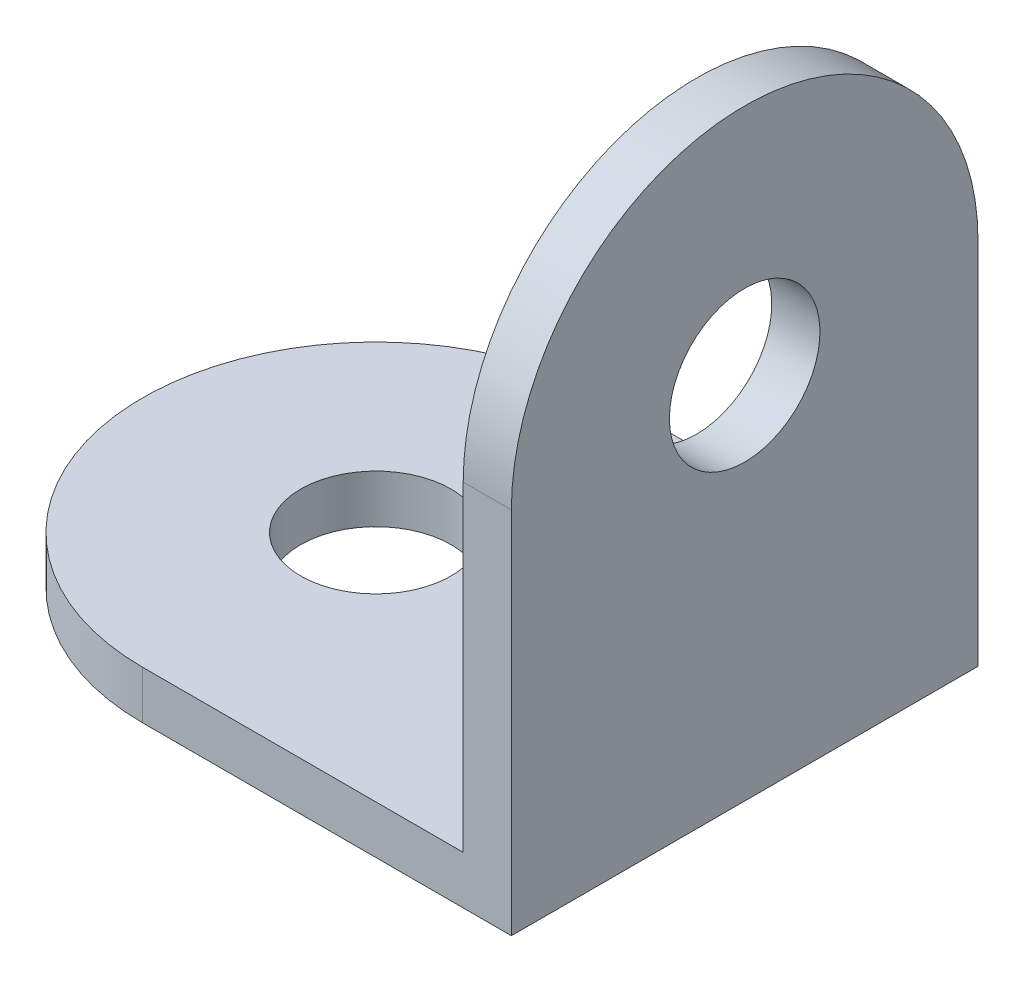
from build123d import *

# Parameters (mm, degrees)
EXTRUDE_1_DEPTH     = 15.5
CUT_EXTRUDE_1_DEPTH = 15.5
CUT_EXTRUDE_2_DEPTH = 15.5
SKETCH_4_R          = 2.5
CUT_EXTRUDE_3_DEPTH = 15.5
SKETCH_5_R          = 2.5
CUT_EXTRUDE_4_DEPTH = 15.5


with BuildPart() as part:
    # 草图1 → 凸台-拉伸1 (new body)
    with BuildSketch(Plane.XY):
        Polygon((0, 0), (-20, 0), (-20, 1.6), (-1.6, 1.6), (-1.6, 20), (0, 20), align=None)
    extrude(amount=EXTRUDE_1_DEPTH)

    # 草图2 → 切除-拉伸1 (cut)
    with BuildSketch(Plane.ZY.offset(1.6)):
        with BuildLine():
            Line((0, 20), (0, 12.25))
            ThreePointArc((0, 12.25), (2.269922446, 17.730077554), (7.75, 20))
            Line((7.75, 20), (0, 20))
        make_face()
        with BuildLine():
            ThreePointArc((7.75, 20), (13.230077554, 17.730077554), (15.5, 12.25))
            Line((15.5, 12.25), (15.5, 20))
            Line((15.5, 20), (7.75, 20))
        make_face()
    extrude(amount=-CUT_EXTRUDE_1_DEPTH, mode=Mode.SUBTRACT)

    # 草图3 → 切除-拉伸2 (cut)
    with BuildSketch(Plane(origin=(0, 1.6, 0), x_dir=(1, 0, 0), z_dir=(0, 1, 0))):
        with BuildLine():
            ThreePointArc((-12.25, -15.5), (-17.730077554, -13.230077554), (-20, -7.75))
            Line((-20, -7.75), (-20, -15.5))
            Line((-20, -15.5), (-12.25, -15.5))
        make_face()
        with BuildLine():
            ThreePointArc((-20, -7.75), (-17.730077554, -2.269922446), (-12.25, 0))
            Line((-12.25, 0), (-20, 0))
            Line((-20, 0), (-20, -7.75))
        make_face()
    extrude(amount=-CUT_EXTRUDE_2_DEPTH, mode=Mode.SUBTRACT)

    # 草图4 → 切除-拉伸3 (cut)
    with BuildSketch(Plane.ZY.offset(1.6)):
        with Locations((7.75, 12.25)):
            Circle(SKETCH_4_R)
    extrude(amount=-CUT_EXTRUDE_3_DEPTH, mode=Mode.SUBTRACT)

    # 草图5 → 切除-拉伸4 (cut)
    with BuildSketch(Plane(origin=(0, 1.6, 0), x_dir=(1, 0, 0), z_dir=(0, 1, 0))):
        with Locations((-12.25, -7.75)):
            Circle(SKETCH_5_R)
    extrude(amount=-CUT_EXTRUDE_4_DEPTH, mode=Mode.SUBTRACT)


solid = part.part
